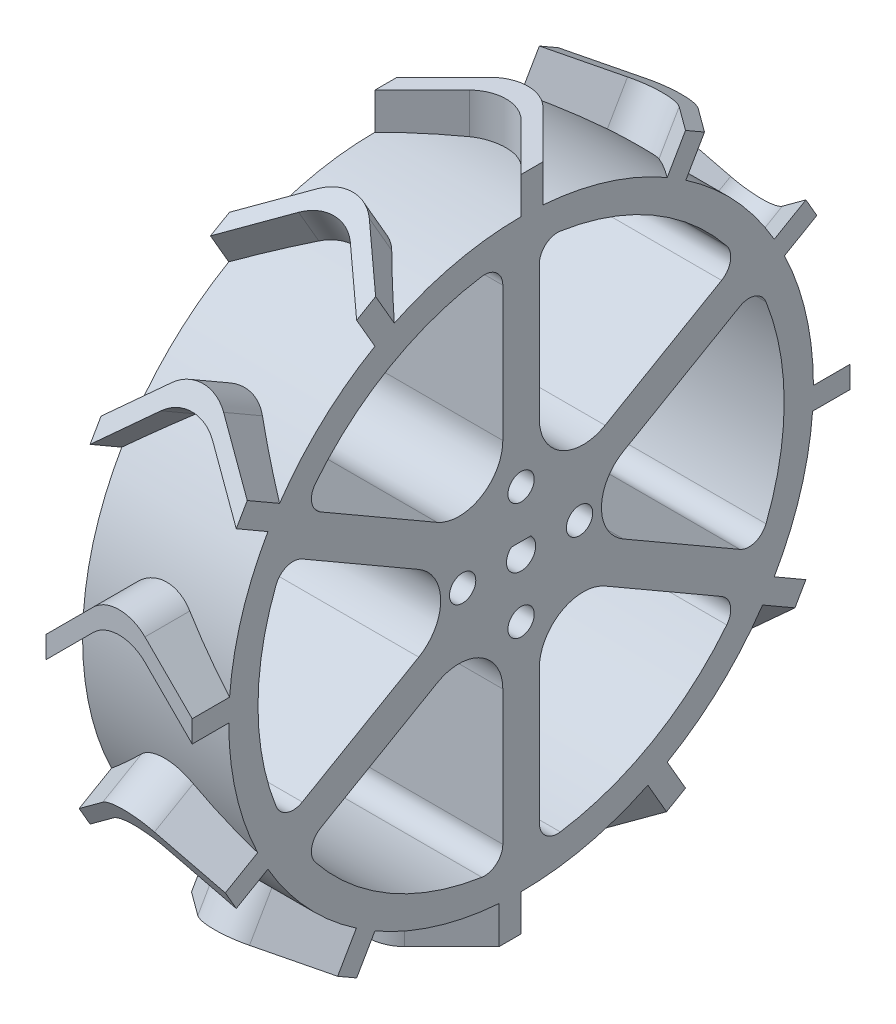
from build123d import *

# Parameters (mm, degrees)
SKETCH2_R                = 40
BOSS_EXTRUDE1_DEPTH      = 20
BOSS_EXTRUDE2_DEPTH      = 45
CIRPATTERN2_COUNT        = 12
CUT_EXTRUDE3_DEPTH       = 20
FILLET1_R                = 6
CIRPATTERN3_COUNT        = 6
FILLET1_OF_CIRPATTERN3_R = 6
CUT_EXTRUDE4_REACH       = 22
SKETCH6_R                = 1.8
CUT_EXTRUDE6_DEPTH       = 21
CUT_EXTRUDE6_DEPTH_BACK  = 1


with BuildPart() as part:
    # Sketch2 → Boss-Extrude1 (new body)
    with BuildSketch(Plane(origin=(0, 0, 0), x_dir=(0, 0, -1), z_dir=(1, 0, 0))):
        Circle(SKETCH2_R)
    extrude(amount=BOSS_EXTRUDE1_DEPTH)

    # Sketch4 → Boss-Extrude2 (add)
    with BuildSketch(Plane(origin=(0, 0, 0), x_dir=(1, 0, 0), z_dir=(0, 1, 0))):
        with BuildLine():
            Line((0, 0), (6.464466, 6.464466))
            ThreePointArc((6.464466, 6.464466), (10, 7.928932), (13.535534, 6.464466))
            Line((13.535534, 6.464466), (20, 0))
            Line((20, 0), (20, 3))
            Line((20, 3), (13.535534, 9.464466))
            ThreePointArc((13.535534, 9.464466), (10, 10.928932), (6.464466, 9.464466))
            Line((6.464466, 9.464466), (0, 3))
            Line((0, 3), (0, 0))
        make_face()
    boss_extrude2 = extrude(amount=BOSS_EXTRUDE2_DEPTH)

    # CirPattern2: Boss-Extrude2 ×12 about axis
    cirpattern2_axis = Axis((0, 0, 0), (1, 0, 0))
    for i in range(1, CIRPATTERN2_COUNT):
        add(boss_extrude2.rotate(cirpattern2_axis, i * 360 / CIRPATTERN2_COUNT))

    # Sketch5 → Cut-Extrude3 (cut)
    with BuildSketch(Plane.ZY):
        with BuildLine():
            Line((2.5, 33.124764), (2.5, 4.330127))
            Line((2.5, 4.330127), (27.436887, 18.727446))
            ThreePointArc((27.436887, 18.727446), (28.643353, 20.427993), (28.141133, 22.451652))
            ThreePointArc((28.141133, 22.451652), (18, 31.176915), (5.373134, 35.596761))
            ThreePointArc((5.373134, 35.596761), (3.369484, 35.019868), (2.5, 33.124764))
        make_face()
    cut_extrude3 = extrude(amount=-CUT_EXTRUDE3_DEPTH, mode=Mode.SUBTRACT)

    # Fillet1
    fillet1_edges = [part.edges().sort_by_distance(p)[0] for p in [
        (10, 4.330127, 2.5),
    ]]
    fillet(fillet1_edges, radius=FILLET1_R)

    # CirPattern3: Cut-Extrude3 ×6 about axis
    cirpattern3_axis = Axis((0, 0, 0), (1, 0, 0))
    for i in range(1, CIRPATTERN3_COUNT):
        add(cut_extrude3.rotate(cirpattern3_axis, i * 360 / CIRPATTERN3_COUNT), mode=Mode.SUBTRACT)

    # Fillet1 of CirPattern3
    fillet1_of_cirpattern3_edges = [part.edges().sort_by_distance(p)[0] for p in [
        (10, 0, 5),
        (10, -4.330127, 2.5),
        (10, -4.330127, -2.5),
        (10, 0, -5),
        (10, 4.330127, -2.5),
    ]]
    fillet(fillet1_of_cirpattern3_edges, radius=FILLET1_OF_CIRPATTERN3_R)

    # Sketch6 → Cut-Extrude4 (cut, up to next)
    with BuildSketch(Plane.ZY, mode=Mode.PRIVATE) as cut_extrude4_sk1:
        with Locations((0, 8)):
            Circle(SKETCH6_R)
    cut_extrude4_tool1 = extrude(cut_extrude4_sk1.sketch, amount=-CUT_EXTRUDE4_REACH, mode=Mode.PRIVATE) & part.part
    add(cut_extrude4_tool1.solids().sort_by_distance((0, 8, 0))[0], mode=Mode.SUBTRACT)
    # Sketch6 → Cut-Extrude4 (cut, up to next)
    with BuildSketch(Plane.ZY, mode=Mode.PRIVATE) as cut_extrude4_sk2:
        with Locations((8, 0)):
            Circle(SKETCH6_R)
    cut_extrude4_tool2 = extrude(cut_extrude4_sk2.sketch, amount=-CUT_EXTRUDE4_REACH, mode=Mode.PRIVATE) & part.part
    add(cut_extrude4_tool2.solids().sort_by_distance((0, 0, 8))[0], mode=Mode.SUBTRACT)
    # Sketch6 → Cut-Extrude4 (cut, up to next)
    with BuildSketch(Plane.ZY, mode=Mode.PRIVATE) as cut_extrude4_sk3:
        with Locations((0, -8)):
            Circle(SKETCH6_R)
    cut_extrude4_tool3 = extrude(cut_extrude4_sk3.sketch, amount=-CUT_EXTRUDE4_REACH, mode=Mode.PRIVATE) & part.part
    add(cut_extrude4_tool3.solids().sort_by_distance((0, -8, 0))[0], mode=Mode.SUBTRACT)
    # Sketch6 → Cut-Extrude4 (cut, up to next)
    with BuildSketch(Plane.ZY, mode=Mode.PRIVATE) as cut_extrude4_sk4:
        with Locations((-8, 0)):
            Circle(SKETCH6_R)
    cut_extrude4_tool4 = extrude(cut_extrude4_sk4.sketch, amount=-CUT_EXTRUDE4_REACH, mode=Mode.PRIVATE) & part.part
    add(cut_extrude4_tool4.solids().sort_by_distance((0, 0, -8))[0], mode=Mode.SUBTRACT)

    # Sketch8 → Cut-Extrude6 (cut, two sides)
    with BuildSketch(Plane(origin=(0, 0, 0), x_dir=(0, 0, -1), z_dir=(1, 0, 0))) as cut_extrude6_sk:
        with BuildLine():
            Line((1.322876, 1.5), (-1.322876, 1.5))
            ThreePointArc((-1.322876, 1.5), (0, -2), (1.322876, 1.5))
        make_face()
    extrude(amount=CUT_EXTRUDE6_DEPTH, mode=Mode.SUBTRACT)
    extrude(cut_extrude6_sk.sketch, amount=-CUT_EXTRUDE6_DEPTH_BACK, mode=Mode.SUBTRACT)


solid = part.part
